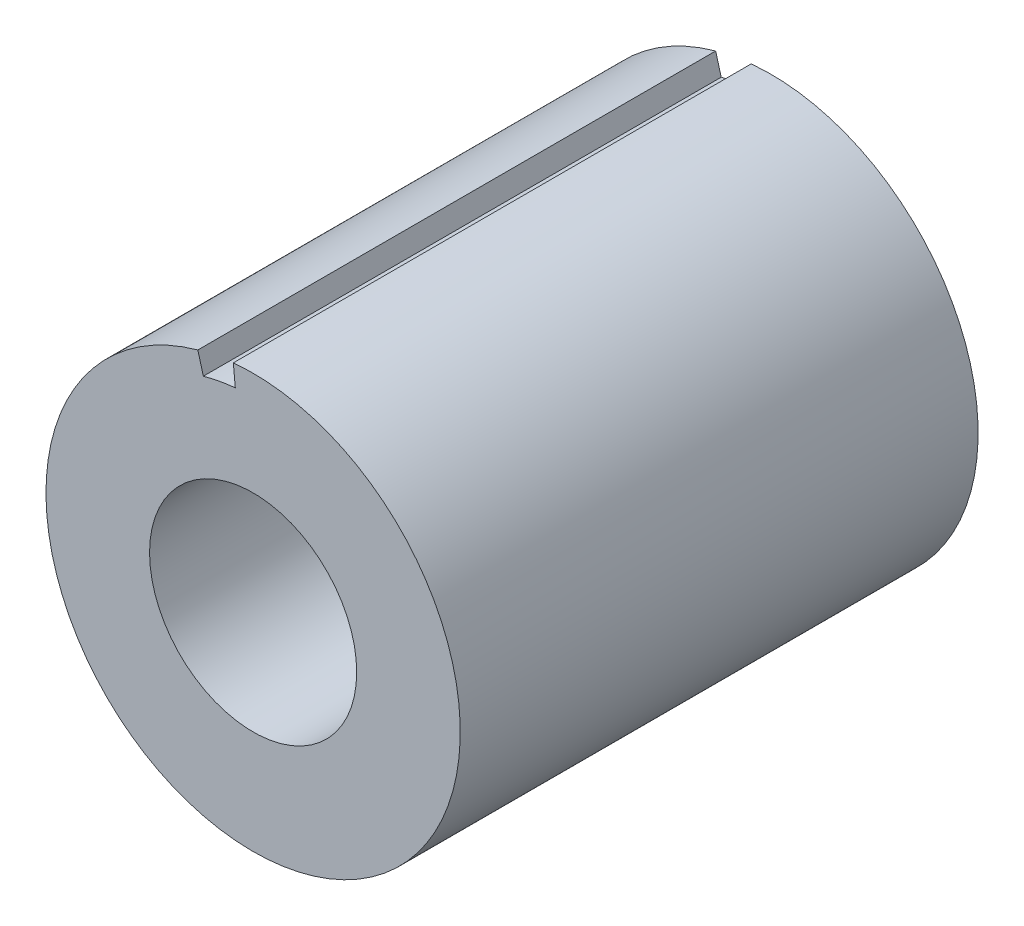
from build123d import *

# Parameters (mm, degrees)
SKETCH1_R           = 4
SKETCH1_R_2         = 2
BOSS_EXTRUDE1_DEPTH = 10
CUT_EXTRUDE1_DEPTH  = 11


with BuildPart() as part:
    # Sketch1 → Boss-Extrude1 (new body)
    with BuildSketch(Plane.XY):
        Circle(SKETCH1_R)
        Circle(SKETCH1_R_2, mode=Mode.SUBTRACT)
    extrude(amount=BOSS_EXTRUDE1_DEPTH)

    # Sketch2 → Cut-Extrude1 (cut)
    with BuildSketch(Plane.XY.offset(10)):
        with BuildLine():
            Line((-0.961093553, 3.469336995), (-1.43156592, 5.16763908))
            ThreePointArc((-1.43156592, 5.16763908), (-0.975728957, 5.272743844), (-0.512466108, 5.337719844))
            Line((-0.512466108, 5.337719844), (-0.344048336, 3.583522114))
            ThreePointArc((-0.344048336, 3.583522114), (-0.65506366, 3.539899942), (-0.961093553, 3.469336995))
        make_face()
    extrude(amount=-CUT_EXTRUDE1_DEPTH, mode=Mode.SUBTRACT)


solid = part.part
